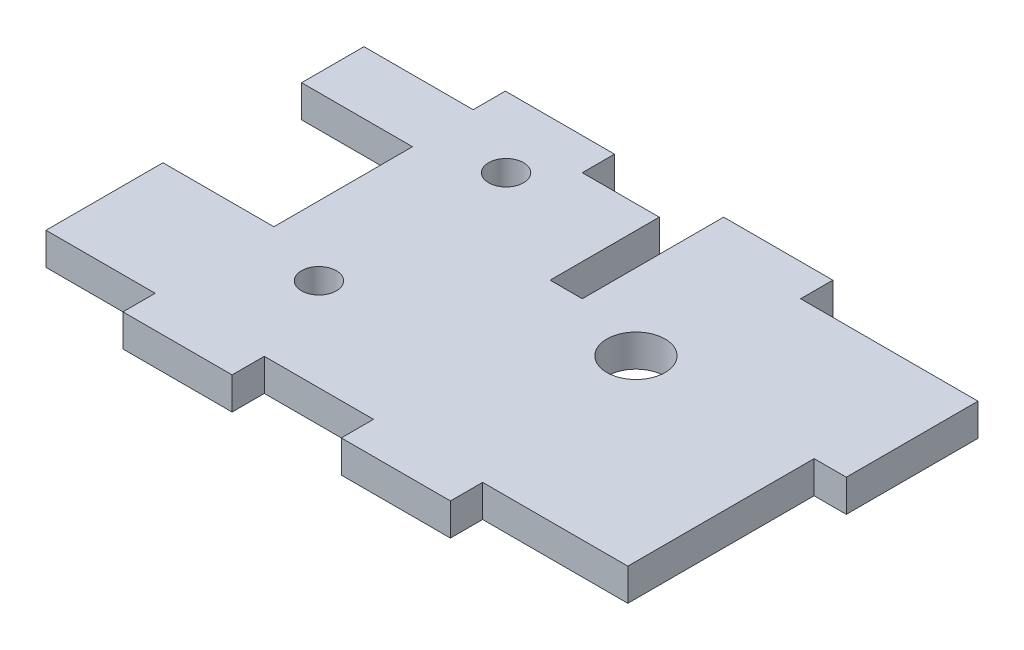
from build123d import *

# Parameters (mm, degrees)
SKETCH1_W               = 48.3108
SKETCH1_H               = 30.03
BOSS_EXTRUDE1_DEPTH     = 2.95
SKETCH2_W               = 10.16
SKETCH2_H               = 12.7
CUT_EXTRUDE1_DEPTH      = 3.95
M3_CLEARANCE_HOLE1_D    = 3.2
SKETCH7_W               = 48.3108
SKETCH7_H               = 2.95
BOSS_EXTRUDE2_DEPTH     = 5
SKETCH6_W               = 10
SKETCH6_H               = 2.95
CUT_EXTRUDE2_DEPTH      = 3.95
LPATTERN1_COUNT         = 3
LPATTERN1_PITCH         = 20
MIRROR1_COPY_1_SKETCH_W = 10
MIRROR1_COPY_1_SKETCH_H = 2.95
MIRROR1_COPY_1_DEPTH    = 3.95
MIRROR1_COPY_2_SKETCH_W = 10
MIRROR1_COPY_2_SKETCH_H = 2.95
MIRROR1_COPY_2_DEPTH    = 3.95
SKETCH8_W               = 12.065
SKETCH8_H               = 2.95
BOSS_EXTRUDE3_DEPTH     = 7.9392
SKETCH9_W               = 17.065
SKETCH9_H               = 2.95
BOSS_EXTRUDE4_DEPTH     = 4.9892
SKETCH10_R              = 2.667
CUT_EXTRUDE3_DEPTH      = 3.95
SKETCH11_W              = 2.95
SKETCH11_H              = 10
CUT_EXTRUDE4_DEPTH      = 3.95


with BuildPart() as part:
    # Sketch1 → Boss-Extrude1 (new body)
    with BuildSketch(Plane(origin=(0, 0, 0), x_dir=(1, 0, 0), z_dir=(0, 1, 0))):
        Rectangle(SKETCH1_W, SKETCH1_H)
    extrude(amount=BOSS_EXTRUDE1_DEPTH)

    # Sketch2 → Cut-Extrude1 (cut, through all)
    with BuildSketch(Plane(origin=(0, 2.95, 0), x_dir=(1, 0, 0), z_dir=(0, 1, 0))):
        with Locations((-19.0754, 0)):
            Rectangle(SKETCH2_W, SKETCH2_H)
    extrude(amount=-CUT_EXTRUDE1_DEPTH, mode=Mode.SUBTRACT)

    # M3 Clearance Hole1 (through all)
    with Locations(Plane(origin=(0, 2.95, 0), x_dir=(1, 0, 0), z_dir=(0, 1, 0))):
        with Locations((-7.6454, 8.5725), (-7.6454, -8.5725)):
            Hole(M3_CLEARANCE_HOLE1_D / 2)

    # Sketch7 → Boss-Extrude2 (add)
    with BuildSketch(Plane.XY.offset(15.015)):
        with Locations((0, 1.475)):
            Rectangle(SKETCH7_W, SKETCH7_H)
    extrude(amount=BOSS_EXTRUDE2_DEPTH)

    # Sketch6 → Cut-Extrude2 (cut, through all)
    with BuildSketch(Plane(origin=(0, 2.95, 0), x_dir=(1, 0, 0), z_dir=(0, 1, 0))):
        with Locations((-19.1554, -18.54)):
            Rectangle(SKETCH6_W, SKETCH6_H)
    cut_extrude2 = extrude(amount=-CUT_EXTRUDE2_DEPTH, mode=Mode.SUBTRACT)

    # LPattern1: Cut-Extrude2 ×3
    with Locations(*[(i * LPATTERN1_PITCH, 0, 0) for i in range(1, LPATTERN1_COUNT)]):
        add(cut_extrude2, mode=Mode.SUBTRACT)

    # Mirror1: Cut-Extrude2 across plane
    add(cut_extrude2.mirror(Plane.XY.offset(2.5)), mode=Mode.SUBTRACT)

    # Mirror1 copy 1 sketch → Mirror1 copy 1 (cut, through all)
    with BuildSketch(Plane(origin=(20, 2.95, 5), x_dir=(1, 0, 0), z_dir=(0, 1, 0))):
        with Locations((-19.1554, 18.54)):
            Rectangle(MIRROR1_COPY_1_SKETCH_W, MIRROR1_COPY_1_SKETCH_H)
    extrude(amount=-MIRROR1_COPY_1_DEPTH, mode=Mode.SUBTRACT)

    # Mirror1 copy 2 sketch → Mirror1 copy 2 (cut, through all)
    with BuildSketch(Plane(origin=(40, 2.95, 5), x_dir=(1, 0, 0), z_dir=(0, 1, 0))):
        with Locations((-19.1554, 18.54)):
            Rectangle(MIRROR1_COPY_2_SKETCH_W, MIRROR1_COPY_2_SKETCH_H)
    extrude(amount=-MIRROR1_COPY_2_DEPTH, mode=Mode.SUBTRACT)

    # Sketch8 → Boss-Extrude3 (add)
    with BuildSketch(Plane(origin=(24.1554, 0, 0), x_dir=(0, 0, -1), z_dir=(1, 0, 0))):
        with Locations((6.0325, 1.475)):
            Rectangle(SKETCH8_W, SKETCH8_H)
    extrude(amount=BOSS_EXTRUDE3_DEPTH)

    # Sketch9 → Boss-Extrude4 (add)
    with BuildSketch(Plane(origin=(24.1554, 0, 0), x_dir=(0, 0, -1), z_dir=(1, 0, 0))):
        with Locations((-8.5325, 1.475)):
            Rectangle(SKETCH9_W, SKETCH9_H)
    extrude(amount=BOSS_EXTRUDE4_DEPTH)

    # Sketch10 → Cut-Extrude3 (cut, through all)
    with BuildSketch(Plane.XZ):
        with Locations((12.827, 0)):
            Circle(SKETCH10_R)
    extrude(amount=-CUT_EXTRUDE3_DEPTH, mode=Mode.SUBTRACT)

    # Sketch11 → Cut-Extrude4 (cut, through all)
    with BuildSketch(Plane.XZ):
        with Locations((4.3696, -7.065)):
            Rectangle(SKETCH11_W, SKETCH11_H)
    extrude(amount=-CUT_EXTRUDE4_DEPTH, mode=Mode.SUBTRACT)


solid = part.part
